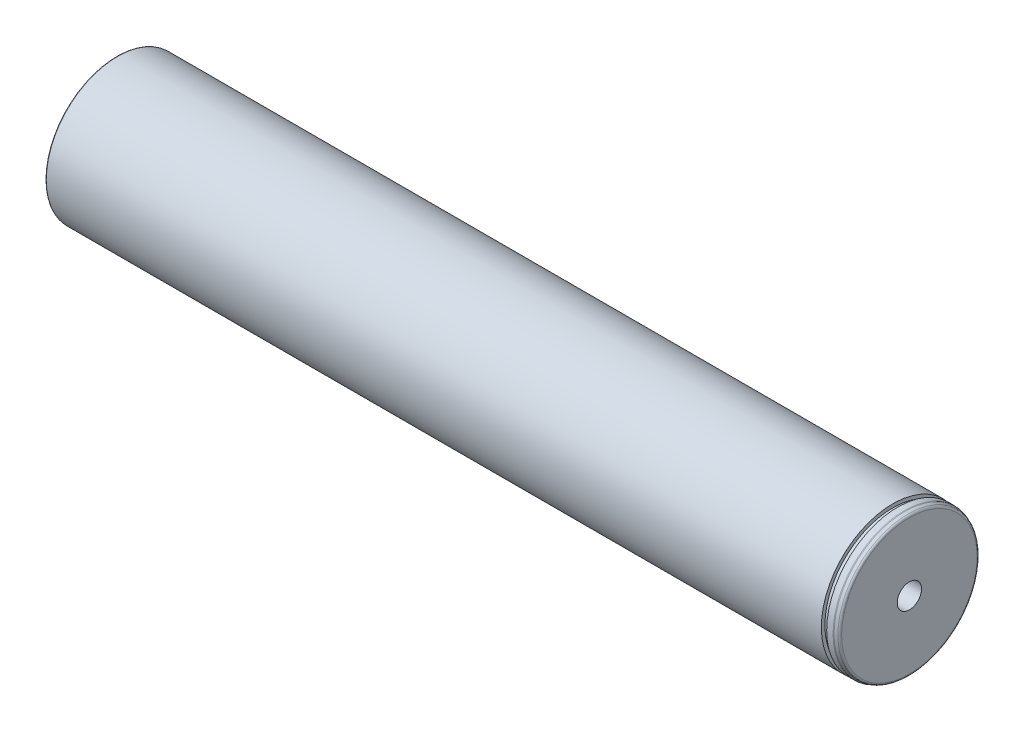
from build123d import *


with BuildPart() as part:
    # Sketch1 → Base-Revolve (revolve)
    with BuildSketch(Plane.XY):
        with BuildLine():
            Line((163, 30), (0, 30))
            Line((0, 30), (-162.6, 30))
            ThreePointArc((-162.6, 30), (-162.882842712, 29.882842712), (-163, 29.6))
            Line((-163, 29.6), (-163, 28.4))
            ThreePointArc((-163, 28.4), (-163.117157288, 28.117157288), (-163.4, 28))
            Line((-163.4, 28), (-164, 28))
            Line((-164, 28), (-164, 25.230940108))
            ThreePointArc((-164, 25.230940108), (-164.053589838, 25.030940108), (-164.2, 24.884529946))
            Line((-164.2, 24.884529946), (-167.8, 22.806068977))
            ThreePointArc((-167.8, 22.806068977), (-167.946410162, 22.659658816), (-168, 22.459658816))
            Line((-168, 22.459658816), (-168, 5.1))
            Line((-168, 5.1), (-148, 5.1))
            Line((-148, 5.1), (-145.055513627, 0))
            Line((-145.055513627, 0), (147.055513627, 0))
            Line((147.055513627, 0), (150, 5.1))
            Line((150, 5.1), (170, 5.1))
            Line((170, 5.1), (170, 28.471851993))
            ThreePointArc((170, 28.471851993), (169.819152044, 29.04542843), (169.342020143, 29.411544614))
            Line((169.342020143, 29.411544614), (168.165693163, 29.839692621))
            ThreePointArc((168.165693163, 29.839692621), (167.997321197, 29.884807753), (167.823673019, 29.9))
            Line((167.823673019, 29.9), (165.15, 29.9))
            Line((165.15, 29.9), (165.15, 28.5))
            Line((165.15, 28.5), (163, 28.5))
            Line((163, 28.5), (163, 30))
        make_face()
    revolve(axis=Axis((-168, 0, 0), (1, 0, 0)))


solid = part.part
